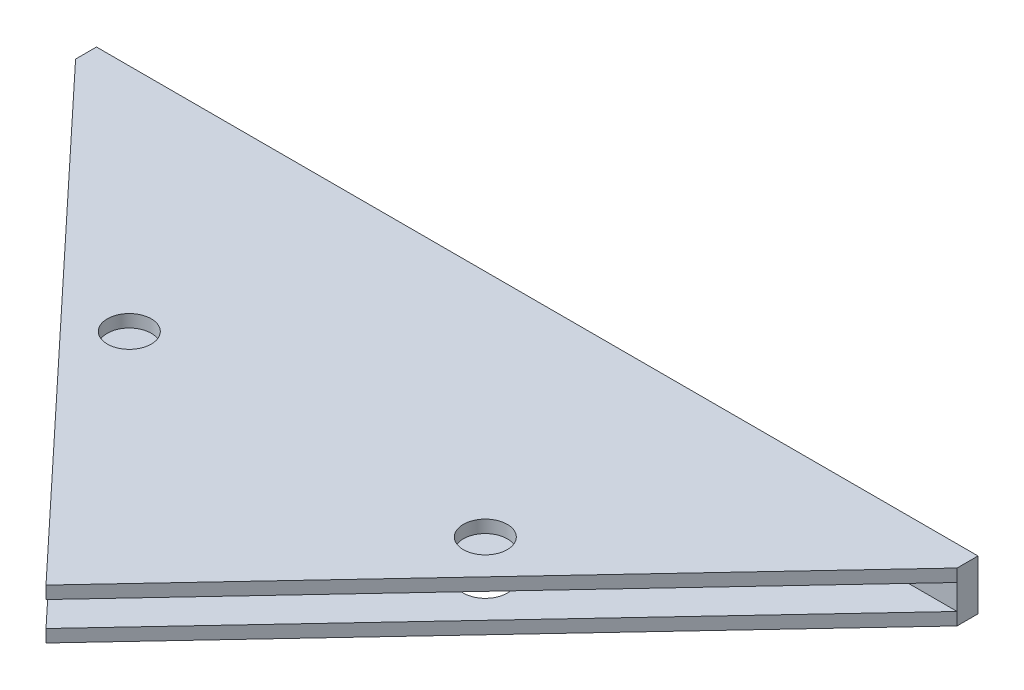
from build123d import *

# Parameters (mm, degrees)
SKETCH4_R           = 2.1
BOSS_EXTRUDE3_DEPTH = 1.2
SKETCH5_W           = 84.339489928
SKETCH5_H           = 2
BOSS_EXTRUDE4_DEPTH = 2.4
SKETCH6_R           = 2.1
BOSS_EXTRUDE5_DEPTH = 1.2


with BuildPart() as part:
    # Sketch4 → Boss-Extrude3 (new body)
    with BuildSketch(Plane(origin=(0, 0, 0), x_dir=(1, 0, 0), z_dir=(0, 1, 0))):
        Polygon((39.4127274, 47.640295112), (-2.757017564, 47.640295112), (-2.757017564, 45.640295112), (39.4127274, 0.640295112), align=None)
        with Locations((22.381300815, 25.64100497)):
            Circle(SKETCH4_R, mode=Mode.SUBTRACT)
        Polygon((81.582472364, 47.640295112), (39.4127274, 47.640295112), (39.4127274, 0.640295112), (81.582472364, 45.640295112), align=None)
        with Locations((56.444153985, 25.64100497)):
            Circle(SKETCH4_R, mode=Mode.SUBTRACT)
    extrude(amount=BOSS_EXTRUDE3_DEPTH)

    # Sketch5 → Boss-Extrude4 (add)
    with BuildSketch(Plane(origin=(0, 0, 0), x_dir=(-1, 0, 0), z_dir=(0, -1, 0))):
        with Locations((-39.4127274, 46.640295112)):
            Rectangle(SKETCH5_W, SKETCH5_H)
    extrude(amount=BOSS_EXTRUDE4_DEPTH)

    # Sketch6 → Boss-Extrude5 (add)
    with BuildSketch(Plane(origin=(0, -2.4, 0), x_dir=(-1, 0, 0), z_dir=(0, -1, 0))):
        Polygon((2.757017564, 47.640295112), (-81.582472364, 47.640295112), (-81.582472364, 45.640295112), (-39.4127274, 0.640295112), (2.757017564, 45.640295112), align=None)
        with Locations((-22.381300815, 25.64100497)):
            Circle(SKETCH6_R, mode=Mode.SUBTRACT)
        with Locations((-56.444153985, 25.64100497)):
            Circle(SKETCH6_R, mode=Mode.SUBTRACT)
    extrude(amount=BOSS_EXTRUDE5_DEPTH)


solid = part.part
